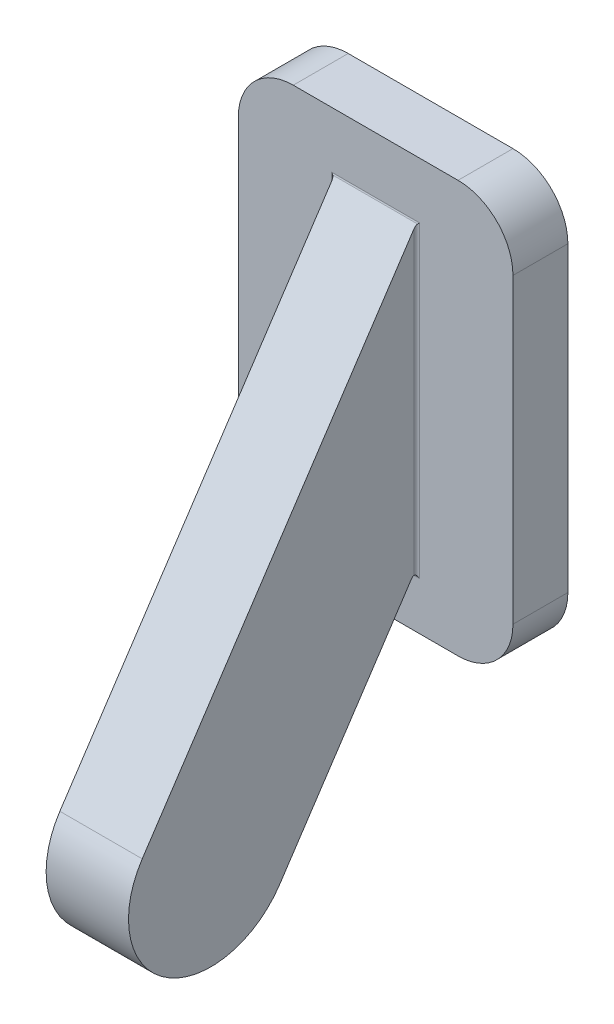
from build123d import *

# Parameters (mm, degrees)
SKETCH1_W           = 10
SKETCH1_H           = 15
BOSS_EXTRUDE1_DEPTH = 2
BOSS_EXTRUDE2_DEPTH = 1.5
FILLET1_R           = 2
FILLET2_R           = 0.1


with BuildPart() as part:
    # Sketch1 → Boss-Extrude1 (new body)
    with BuildSketch(Plane.XY):
        Rectangle(SKETCH1_W, SKETCH1_H)
    extrude(amount=BOSS_EXTRUDE1_DEPTH)

    # Sketch3 → Boss-Extrude2 (add, symmetric)
    with BuildSketch(Plane(origin=(0, 0, 0), x_dir=(0, 0, -1), z_dir=(1, 0, 0))):
        with BuildLine():
            Line((-2, 5.427204202), (-12, -9.648363026))
            ThreePointArc((-12, -9.648363026), (-11.158312395, -13.806675422), (-7, -12.964987817))
            Line((-7, -12.964987817), (-2, -5.427204202))
            Line((-2, -5.427204202), (-2, 5.427204202))
        make_face()
    extrude(amount=BOSS_EXTRUDE2_DEPTH, both=True)

    # Fillet1
    fillet1_edges = [part.edges().sort_by_distance(p)[0] for p in [
        (5, -7.5, 1),
        (-5, -7.5, 1),
        (-5, 7.5, 1),
        (5, 7.5, 1),
    ]]
    fillet(fillet1_edges, radius=FILLET1_R)

    # Fillet2
    fillet2_edges = [part.edges().sort_by_distance(p)[0] for p in [
        (-1.5, 0, 2),
        (0, -5.427204202, 2),
        (0, 5.427204202, 2),
        (1.5, 0, 2),
    ]]
    fillet(fillet2_edges, radius=FILLET2_R)


solid = part.part
